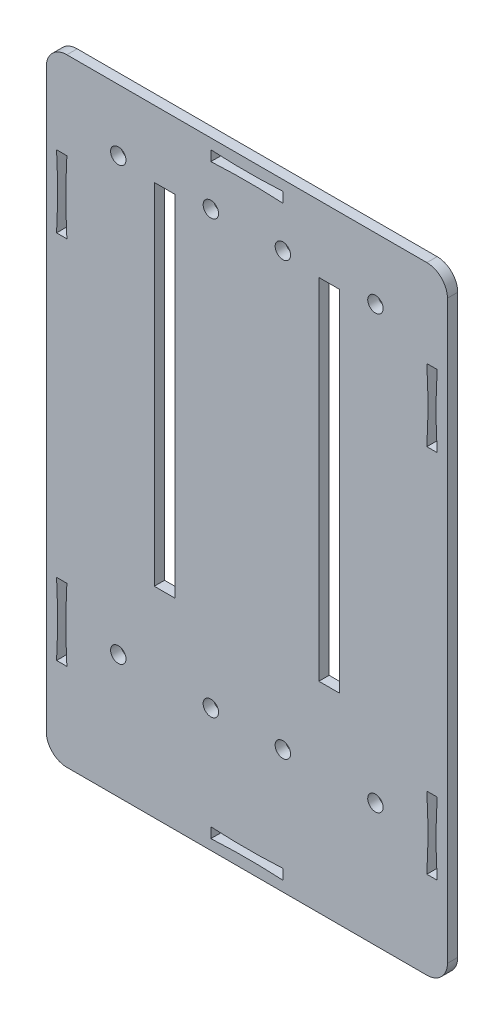
from build123d import *

# Parameters (mm, degrees)
SKETCH1_W              = 78
SKETCH1_H              = 120
SKETCH1_R              = 1.5
SKETCH1_W_2            = 4
SKETCH1_H_2            = 68
MAIN_SLIDER_TOP_DEPTH  = 2
SLIDE_TOP_CONTOURING_R = 4


with BuildPart() as part:
    # Sketch1 → Main Slider Top (new body)
    with BuildSketch(Plane.XY):
        with Locations((39, 60)):
            Rectangle(SKETCH1_W, SKETCH1_H)
        with Locations((14, 108)):
            Circle(SKETCH1_R, mode=Mode.SUBTRACT)
        with Locations((32, 108)):
            Circle(SKETCH1_R, mode=Mode.SUBTRACT)
        with Locations((14, 24)):
            Circle(SKETCH1_R, mode=Mode.SUBTRACT)
        with Locations((32, 24)):
            Circle(SKETCH1_R, mode=Mode.SUBTRACT)
        with Locations((46, 108)):
            Circle(SKETCH1_R, mode=Mode.SUBTRACT)
        with Locations((64, 108)):
            Circle(SKETCH1_R, mode=Mode.SUBTRACT)
        with Locations((46, 24)):
            Circle(SKETCH1_R, mode=Mode.SUBTRACT)
        with Locations((64, 24)):
            Circle(SKETCH1_R, mode=Mode.SUBTRACT)
        with Locations((23, 73)):
            Rectangle(SKETCH1_W_2, SKETCH1_H_2, mode=Mode.SUBTRACT)
        with Locations((55, 73)):
            Rectangle(SKETCH1_W_2, SKETCH1_H_2, mode=Mode.SUBTRACT)
        with BuildLine():
            Line((32, 118), (32, 116))
            add(Edge.make_bspline(
                [(32, 116), (39, 116.4), (46, 116)],
                knots=[0, 0, 0, 1, 1, 1], degree=2))
            Line((46, 116), (46, 118))
            add(Edge.make_bspline(
                [(32, 118), (39, 117.6), (46, 118)],
                knots=[0, 0, 0, 1, 1, 1], degree=2))
        make_face(mode=Mode.SUBTRACT)
        with BuildLine():
            Line((46, 2), (46, 4))
            add(Edge.make_bspline(
                [(32, 4), (39, 3.6), (46, 4)],
                knots=[0, 0, 0, 1, 1, 1], degree=2))
            Line((32, 4), (32, 2))
            add(Edge.make_bspline(
                [(32, 2), (39, 2.4), (46, 2)],
                knots=[0, 0, 0, 1, 1, 1], degree=2))
        make_face(mode=Mode.SUBTRACT)
        with BuildLine():
            Line((2, 31), (4, 31))
            add(Edge.make_bspline(
                [(4, 17), (3.6, 24), (4, 31)],
                knots=[0, 0, 0, 1, 1, 1], degree=2))
            Line((4, 17), (2, 17))
            add(Edge.make_bspline(
                [(2, 17), (2.4, 24), (2, 31)],
                knots=[0, 0, 0, 1, 1, 1], degree=2))
        make_face(mode=Mode.SUBTRACT)
        with BuildLine():
            Line((76, 17), (74, 17))
            add(Edge.make_bspline(
                [(74, 17), (74.4, 24), (74, 31)],
                knots=[0, 0, 0, 1, 1, 1], degree=2))
            Line((74, 31), (76, 31))
            add(Edge.make_bspline(
                [(76, 17), (75.6, 24), (76, 31)],
                knots=[0, 0, 0, 1, 1, 1], degree=2))
        make_face(mode=Mode.SUBTRACT)
        with BuildLine():
            Line((76, 89), (74, 89))
            add(Edge.make_bspline(
                [(74, 103), (74.4, 96), (74, 89)],
                knots=[0, 0, 0, 1, 1, 1], degree=2))
            Line((74, 103), (76, 103))
            add(Edge.make_bspline(
                [(76, 103), (75.6, 96), (76, 89)],
                knots=[0, 0, 0, 1, 1, 1], degree=2))
        make_face(mode=Mode.SUBTRACT)
        with BuildLine():
            Line((2, 103), (4, 103))
            add(Edge.make_bspline(
                [(4, 103), (3.6, 96), (4, 89)],
                knots=[0, 0, 0, 1, 1, 1], degree=2))
            Line((4, 89), (2, 89))
            add(Edge.make_bspline(
                [(2, 103), (2.4, 96), (2, 89)],
                knots=[0, 0, 0, 1, 1, 1], degree=2))
        make_face(mode=Mode.SUBTRACT)
    extrude(amount=MAIN_SLIDER_TOP_DEPTH)

    # Slide Top Contouring
    slide_top_contouring_edges = [part.edges().sort_by_distance(p)[0] for p in [
        (0, 0, 1),
        (0, 120, 1),
        (78, 120, 1),
        (78, 0, 1),
    ]]
    fillet(slide_top_contouring_edges, radius=SLIDE_TOP_CONTOURING_R)


solid = part.part
